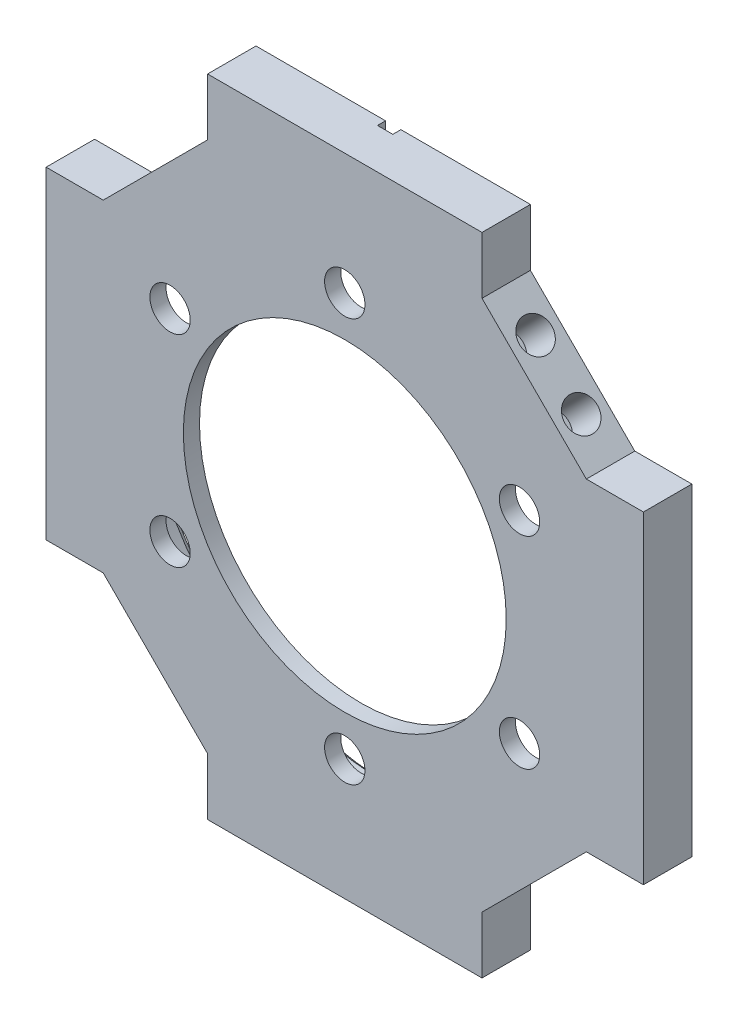
from build123d import *

# Parameters (mm, degrees)
SKETCH1_W               = 74
SKETCH1_H               = 80
SKETCH1_R               = 30
BOSS_EXTRUDE1_DEPTH     = 6
SKETCH2_R               = 30
SKETCH2_R_2             = 20
BOSS_EXTRUDE2_DEPTH     = 2
SKETCH3_R               = 2.5
CUT_EXTRUDE1_DEPTH      = 2
CHAMFER1_SIZE           = 20
SKETCH4_R               = 2
CUT_EXTRUDE2_DEPTH      = 10
MIRROR2_COPY_1_SKETCH_R = 2
MIRROR2_COPY_1_DEPTH    = 10
CHAMFER2_SIZE           = 1
SKETCH7_W               = 1.90476799
SKETCH7_H               = 4.426812408
CUT_EXTRUDE3_DEPTH      = 1
CUT_EXTRUDE4_DEPTH      = 7


with BuildPart() as part:
    # Sketch1 → Boss-Extrude1 (new body)
    with BuildSketch(Plane.XY):
        with Locations((37, 40)):
            Rectangle(SKETCH1_W, SKETCH1_H)
        with Locations((37, 40)):
            Circle(SKETCH1_R, mode=Mode.SUBTRACT)
    extrude(amount=BOSS_EXTRUDE1_DEPTH)

    # Sketch2 → Boss-Extrude2 (add)
    with BuildSketch(Plane.XY.offset(6)):
        with Locations((37, 40)):
            Circle(SKETCH2_R)
        with Locations((37, 40)):
            Circle(SKETCH2_R_2, mode=Mode.SUBTRACT)
    extrude(amount=-BOSS_EXTRUDE2_DEPTH)

    # Sketch3 → Cut-Extrude1 (cut)
    with BuildSketch(Plane(origin=(0, 0, 4), x_dir=(-1, 0, 0), z_dir=(0, 0, -1))):
        with Locations((-37, 65)):
            Circle(SKETCH3_R)
        with Locations((-15.349364905, 52.5)):
            Circle(SKETCH3_R)
        with Locations((-15.349364905, 27.5)):
            Circle(SKETCH3_R)
        with Locations((-37, 15)):
            Circle(SKETCH3_R)
        with Locations((-58.650635095, 27.5)):
            Circle(SKETCH3_R)
        with Locations((-58.650635095, 52.5)):
            Circle(SKETCH3_R)
    extrude(amount=-CUT_EXTRUDE1_DEPTH, mode=Mode.SUBTRACT)

    # Chamfer1
    chamfer1_edges = [part.edges().sort_by_distance(p)[0] for p in [
        (0, 80, 3),
        (74, 80, 3),
        (74, 0, 3),
        (0, 0, 3),
    ]]
    chamfer(chamfer1_edges, length=CHAMFER1_SIZE)

    # Sketch4 → Cut-Extrude2 (cut)
    with BuildSketch(Plane(origin=(-30, 30, 0), x_dir=(0, 0, 1), z_dir=(-0.707106781, 0.707106781, 0))):
        with Locations((3, 60.568542495)):
            Circle(SKETCH4_R)
        with Locations((3, 52.568542495)):
            Circle(SKETCH4_R)
    cut_extrude2 = extrude(amount=-CUT_EXTRUDE2_DEPTH, mode=Mode.SUBTRACT)

    # Mirror1: Cut-Extrude2 across plane
    add(cut_extrude2.mirror(Plane.ZY.offset(-37)), mode=Mode.SUBTRACT)

    # Mirror2: Cut-Extrude2 across plane
    add(cut_extrude2.mirror(Plane(origin=(0, 40, 0), x_dir=(0, 0, 1), z_dir=(0, -1, 0))), mode=Mode.SUBTRACT)

    # Mirror2 copy 1 sketch → Mirror2 copy 1 (cut)
    with BuildSketch(Plane(origin=(104, 50, 0), x_dir=(0, 0, 1), z_dir=(0.707106781, -0.707106781, 0))):
        with Locations((3, 60.568542495)):
            Circle(MIRROR2_COPY_1_SKETCH_R)
        with Locations((3, 52.568542495)):
            Circle(MIRROR2_COPY_1_SKETCH_R)
    extrude(amount=-MIRROR2_COPY_1_DEPTH, mode=Mode.SUBTRACT)

    # Chamfer2
    chamfer2_edges = [part.edges().sort_by_distance(p)[0] for p in [
        (7, 40, 0),
    ]]
    chamfer(chamfer2_edges, length=CHAMFER2_SIZE)

    # Sketch7 → Cut-Extrude3 (cut)
    with BuildSketch(Plane(origin=(0, 0, 0), x_dir=(-1, 0, 0), z_dir=(0, 0, -1))):
        with Locations((-37, 77.786593796)):
            Rectangle(SKETCH7_W, SKETCH7_H)
    extrude(amount=-CUT_EXTRUDE3_DEPTH, mode=Mode.SUBTRACT)

    # Sketch8 → Cut-Extrude4 (cut, through all)
    with BuildSketch(Plane.XY.offset(6)):
        Polygon((0, 60), (7.071067812, 60), (20, 72.928932188), (20, 80), align=None)
        Polygon((54, 80), (54, 72.928932188), (66.928932188, 60), (74, 60), align=None)
        Polygon((66.928932188, 20), (74, 20), (54, 0), (54, 7.071067812), align=None)
        Polygon((0, 20), (7.071067812, 20), (20, 7.071067812), (20, 0), align=None)
    extrude(amount=-CUT_EXTRUDE4_DEPTH, mode=Mode.SUBTRACT)


solid = part.part
